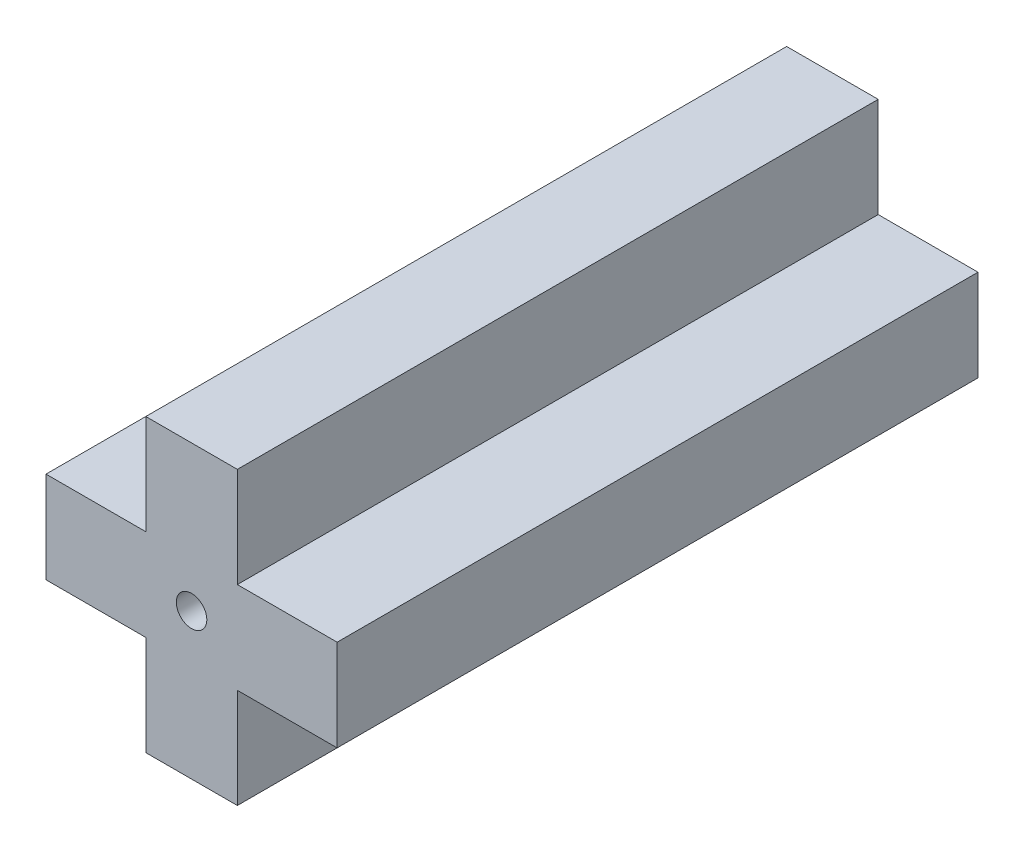
from build123d import *

# Parameters (mm, degrees)
SKETCH2_R           = 0.5
BOSS_EXTRUDE1_DEPTH = 21


with BuildPart() as part:
    # Sketch2 → Boss-Extrude1 (new body)
    with BuildSketch(Plane.XY):
        Polygon((1.5, 0), (4.77, 0), (4.77, 3), (1.5, 3), (1.5, 6.27), (-1.5, 6.27), (-1.5, 3), (-4.77, 3), (-4.77, 0), (-1.5, 0), (-1.5, -3.27), (1.5, -3.27), align=None)
        with Locations((0, 1.5)):
            Circle(SKETCH2_R, mode=Mode.SUBTRACT)
    extrude(amount=BOSS_EXTRUDE1_DEPTH)


solid = part.part
